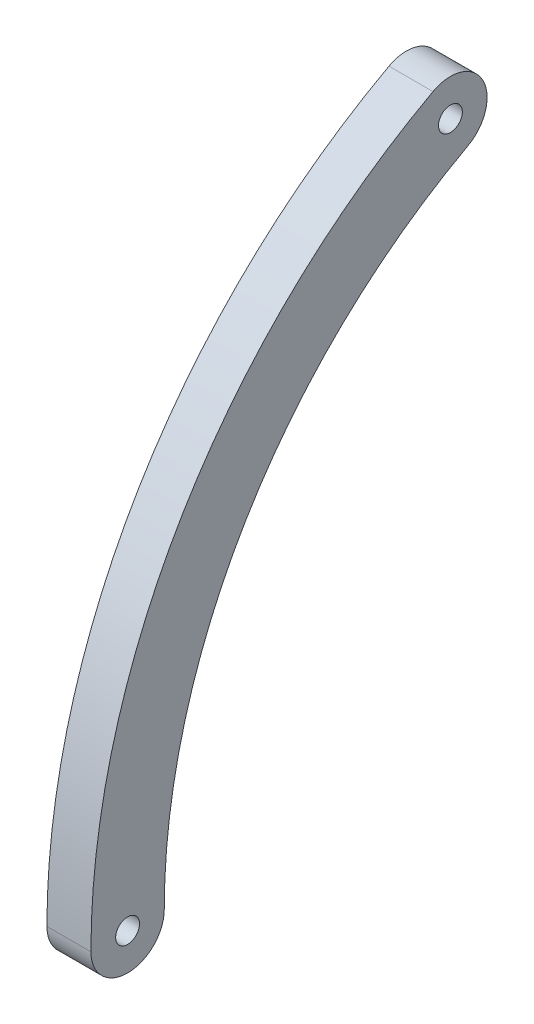
from build123d import *

# Parameters (mm, degrees)
ESQUISSE1_R        = 1.031875
BOSS_EXTRU_1_DEPTH = 3.81


with BuildPart() as part:
    # Esquisse1 → Boss.-Extru.1 (new body)
    with BuildSketch(Plane(origin=(0, 0, 0), x_dir=(0, 0, -1), z_dir=(1, 0, 0))):
        with BuildLine():
            ThreePointArc((-50.165, 0), (-43.093852353, 25.679702381), (-23.873876134, 44.119896457))
            ThreePointArc((-23.873876134, 44.119896457), (-22.592482442, 48.423299785), (-26.895885771, 49.704693477))
            ThreePointArc((-26.895885771, 49.704693477), (-48.548770372, 28.930297619), (-56.515, 0))
            ThreePointArc((-56.515, 0), (-53.34, -3.175), (-50.165, 0))
        make_face()
        with Locations((-53.34, 0)):
            Circle(ESQUISSE1_R, mode=Mode.SUBTRACT)
        with Locations((-25.384880952, 46.912294967)):
            Circle(ESQUISSE1_R, mode=Mode.SUBTRACT)
    extrude(amount=BOSS_EXTRU_1_DEPTH)


solid = part.part
